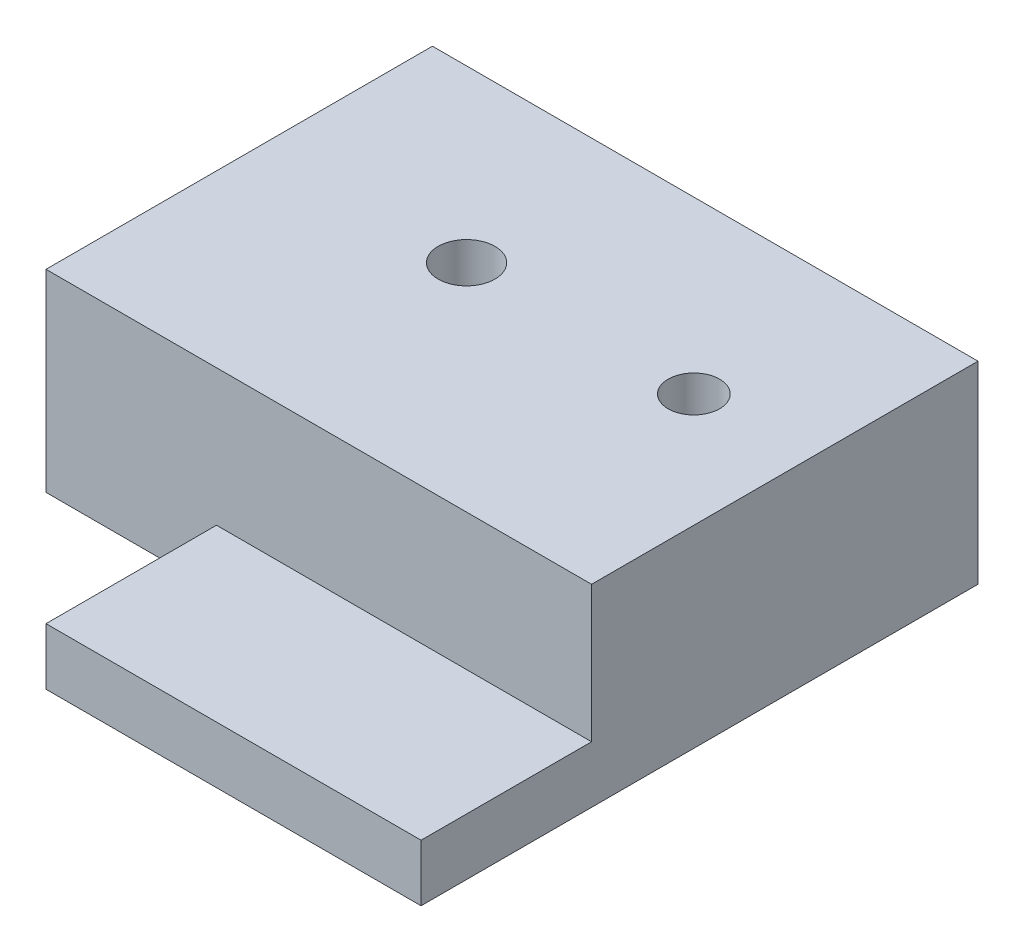
from build123d import *

# Parameters (mm, degrees)
SKETCH1_R           = 2.5
SKETCH1_R_2         = 2
BOSS_EXTRUDE1_DEPTH = 5
SKETCH2_W           = 48
SKETCH2_H           = 34
SKETCH2_R           = 2.5
SKETCH2_R_2         = 2.264702838
BOSS_EXTRUDE2_DEPTH = 12


with BuildPart() as part:
    # Sketch1 → Boss-Extrude1 (new body)
    with BuildSketch(Plane(origin=(0, 0, 0), x_dir=(1, 0, 0), z_dir=(0, 1, 0))):
        Polygon((15, 15), (15, 0), (48, 0), (48, 49), (0, 49), (0, 15), align=None)
        with Locations((18, 34)):
            Circle(SKETCH1_R, mode=Mode.SUBTRACT)
        with Locations((38, 34)):
            Circle(SKETCH1_R_2, mode=Mode.SUBTRACT)
    extrude(amount=BOSS_EXTRUDE1_DEPTH)

    # Sketch2 → Boss-Extrude2 (add)
    with BuildSketch(Plane(origin=(0, 5, 0), x_dir=(1, 0, 0), z_dir=(0, 1, 0))):
        with Locations((24, 32)):
            Rectangle(SKETCH2_W, SKETCH2_H)
        with Locations((18, 34)):
            Circle(SKETCH2_R, mode=Mode.SUBTRACT)
        with Locations((38, 34)):
            Circle(SKETCH2_R_2, mode=Mode.SUBTRACT)
    extrude(amount=BOSS_EXTRUDE2_DEPTH)


solid = part.part
